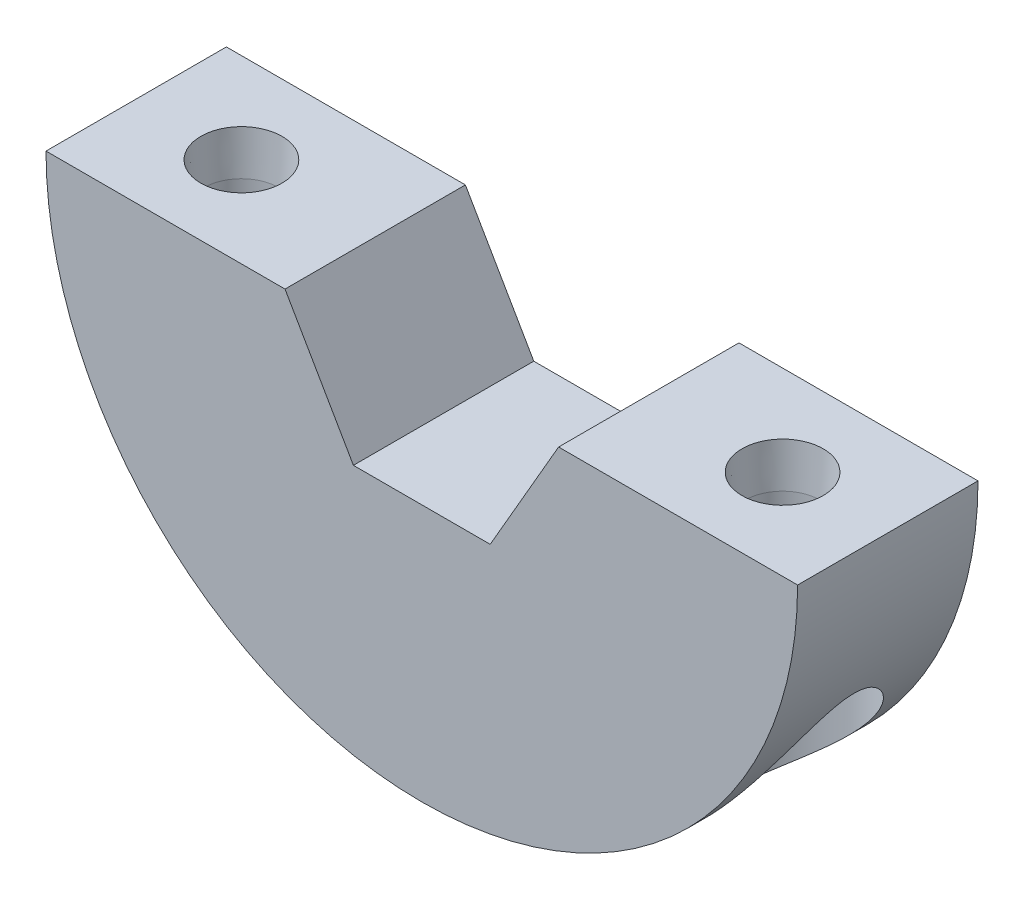
from build123d import *

# Parameters (mm, degrees)
BOSS_EXTRUDE1_DEPTH                          = 12
SKETCH2_R                                    = 4.75
CUT_EXTRUDE1_DEPTH                           = 35
SKETCH3_R                                    = 2.05
CUT_EXTRUDE2_DEPTH                           = 35
CUT_EXTRUDE3_DEPTH                           = 20
CSK_FOR_M3_CROSS_COUNTERSUNK_HEAD_SC_2_COUNT = 2
CSK_FOR_M3_CROSS_COUNTERSUNK_HEAD_SC_2_PITCH = 36


with BuildPart() as part:
    # Sketch1 → Boss-Extrude1 (new body)
    with BuildSketch(Plane.XY):
        with BuildLine():
            Line((-9.1, 0), (-25, 0))
            ThreePointArc((-25, 0), (0, -25), (25, 0))
            Line((25, 0), (9.211282306, 0))
            Line((9.211282306, 0), (9.1, 0))
            Line((9.1, 0), (-9.1, 0))
        make_face()
    extrude(amount=BOSS_EXTRUDE1_DEPTH)

    # Sketch2 → Cut-Extrude1 (cut)
    with BuildSketch(Plane(origin=(0, -40, 0), x_dir=(1, 0, 0), z_dir=(0, 1, 0))):
        with Locations((18, -6)):
            Circle(SKETCH2_R)
        with Locations((-18, -6)):
            Circle(SKETCH2_R)
    extrude(amount=CUT_EXTRUDE1_DEPTH, mode=Mode.SUBTRACT)

    # Sketch3 → Cut-Extrude2 (cut)
    with BuildSketch(Plane.XZ.offset(5)):
        with Locations((18, 6)):
            Circle(SKETCH3_R)
        with Locations((-18, 6)):
            Circle(SKETCH3_R)
    extrude(amount=-CUT_EXTRUDE2_DEPTH, mode=Mode.SUBTRACT)

    # Sketch4 → Cut-Extrude3 (cut)
    with BuildSketch(Plane.XY.offset(12)):
        Polygon((9.1, 0), (4.55, 7.880831174), (-4.55, 7.880831174), (-9.1, 0), (-4.55, -7.880831174), (4.55, -7.880831174), align=None)
    extrude(amount=-CUT_EXTRUDE3_DEPTH, mode=Mode.SUBTRACT)

    # Sketch5 → CSK for M3 Cross Countersunk Head Screw1 (revolve, cut)
    with BuildSketch(Plane(origin=(-18, 0, 6), x_dir=(0, 0, 1), z_dir=(1, 0, 0))):
        Polygon((0, 0), (0, 25), (2.5, 25), (2.5, 2.860133251), (2.7, 0), align=None)
    csk_for_m3_cross_countersunk_head_screw1 = revolve(axis=Axis((-18, 6.35, 6), (0, -1, 0)), mode=Mode.SUBTRACT)

    # CSK for M3 Cross Countersunk Head Sc 2: CSK for M3 Cross Countersunk Head Screw1 ×2
    with Locations(*[(i * CSK_FOR_M3_CROSS_COUNTERSUNK_HEAD_SC_2_PITCH, 0, 0) for i in range(1, CSK_FOR_M3_CROSS_COUNTERSUNK_HEAD_SC_2_COUNT)]):
        add(csk_for_m3_cross_countersunk_head_screw1, mode=Mode.SUBTRACT)


solid = part.part
